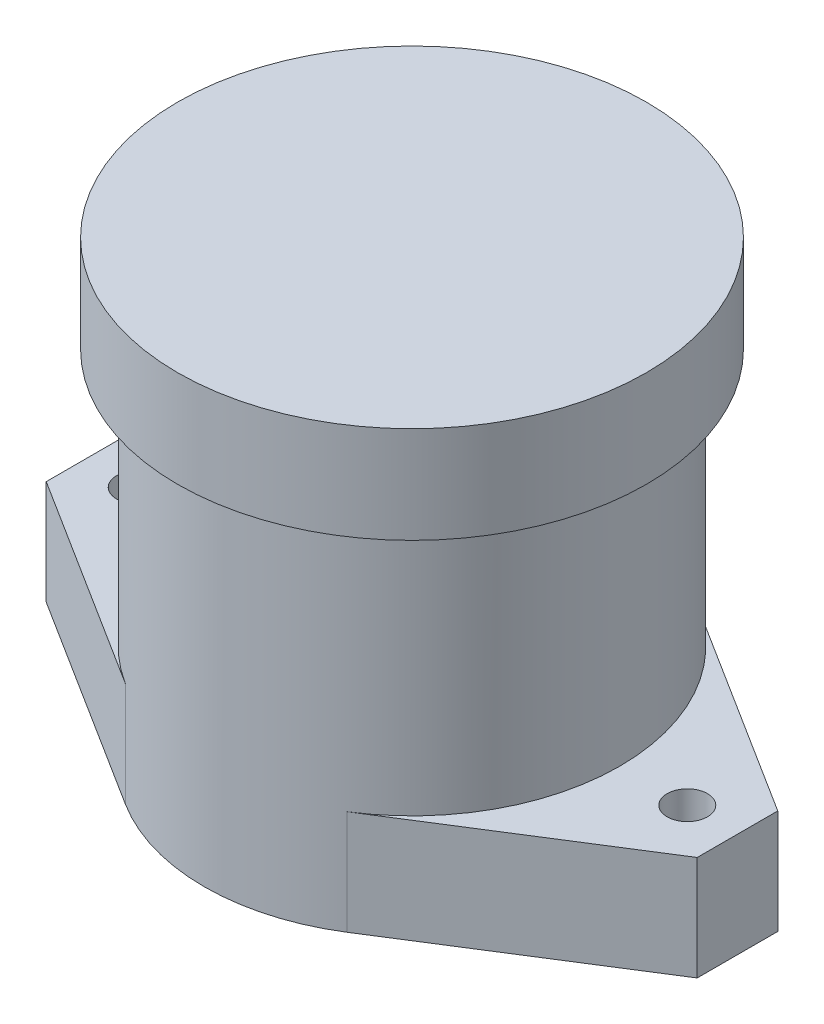
from build123d import *

# Parameters (mm, degrees)
SKETCH1_R           = 2.5
BOSS_EXTRUDE1_DEPTH = 12.954
SKETCH2_R           = 25.781
BOSS_EXTRUDE2_DEPTH = 43.942
SKETCH3_R           = 29.083
BOSS_EXTRUDE3_DEPTH = 12


with BuildPart() as part:
    # Sketch1 → Boss-Extrude1 (new body)
    with BuildSketch(Plane(origin=(0, 0, 0), x_dir=(1, 0, 0), z_dir=(0, 1, 0))):
        with BuildLine():
            Line((-40.386, -5), (-40.386, 5))
            Line((-40.386, 5), (-13.758365761, 21.802920277))
            ThreePointArc((-13.758365761, 21.802920277), (0, 25.781), (13.758365761, 21.802920277))
            Line((13.758365761, 21.802920277), (40.386, 5))
            Line((40.386, 5), (40.386, -5))
            Line((40.386, -5), (13.758365761, -21.802920277))
            ThreePointArc((13.758365761, -21.802920277), (0, -25.781), (-13.758365761, -21.802920277))
            Line((-13.758365761, -21.802920277), (-40.386, -5))
        make_face()
        with Locations((-34.163, 0)):
            Circle(SKETCH1_R, mode=Mode.SUBTRACT)
        with Locations((34.163, 0)):
            Circle(SKETCH1_R, mode=Mode.SUBTRACT)
    extrude(amount=BOSS_EXTRUDE1_DEPTH)

    # Sketch2 → Boss-Extrude2 (add)
    with BuildSketch(Plane(origin=(0, 12.954, 0), x_dir=(1, 0, 0), z_dir=(0, 1, 0))):
        Circle(SKETCH2_R)
    extrude(amount=BOSS_EXTRUDE2_DEPTH)

    # Sketch3 → Boss-Extrude3 (add)
    with BuildSketch(Plane(origin=(0, 56.896, 0), x_dir=(1, 0, 0), z_dir=(0, 1, 0))):
        Circle(SKETCH3_R)
    extrude(amount=-BOSS_EXTRUDE3_DEPTH)


solid = part.part
